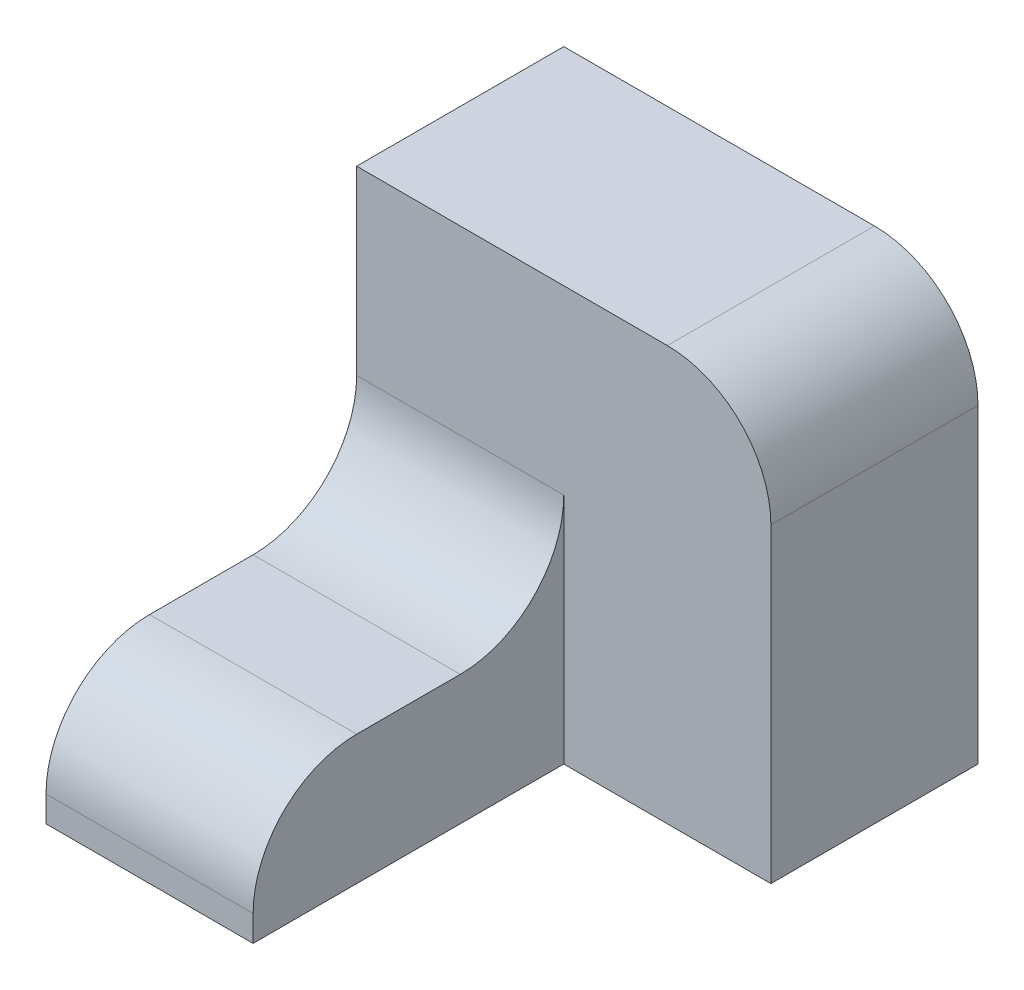
from build123d import *

# Parameters (mm, degrees)
SKETCH1_W           = 20
SKETCH1_H           = 12.5
BOSS_EXTRUDE1_DEPTH = 30
SKETCH2_W           = 40
SKETCH2_H           = 40
BOSS_EXTRUDE2_DEPTH = 20
FILLET1_R           = 10


with BuildPart() as part:
    # Sketch1 → Boss-Extrude1 (new body)
    with BuildSketch(Plane.XY):
        with Locations((-20, -6.25)):
            Rectangle(SKETCH1_W, SKETCH1_H)
    extrude(amount=BOSS_EXTRUDE1_DEPTH)

    # Sketch2 → Boss-Extrude2 (add)
    with BuildSketch(Plane.XY):
        with Locations((-10, 7.5)):
            Rectangle(SKETCH2_W, SKETCH2_H)
    extrude(amount=-BOSS_EXTRUDE2_DEPTH)

    # Fillet1
    fillet1_edges = [part.edges().sort_by_distance(p)[0] for p in [
        (10, 27.5, -10),
        (-20, 0, 30),
        (-20, 0, 0),
    ]]
    fillet(fillet1_edges, radius=FILLET1_R)


solid = part.part
